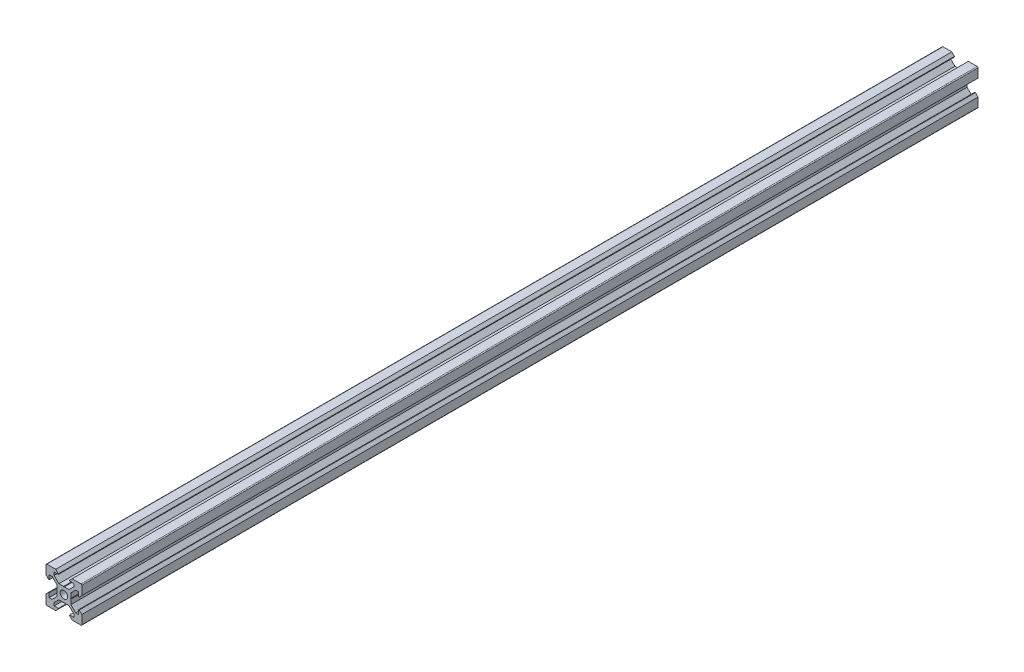
from build123d import *

# Parameters (mm, degrees)
SKETCH1_R           = 2.1
BOSS_EXTRUDE1_DEPTH = 500


with BuildPart() as part:
    # Sketch1 → Boss-Extrude1 (new body)
    with BuildSketch(Plane.XY):
        with BuildLine():
            Line((4.58, -10), (9.5, -10))
            ThreePointArc((9.5, -10), (9.853553391, -9.853553391), (10, -9.5))
            Line((10, -9.5), (10, -4.58))
            Line((10, -4.58), (8.545, -3.125))
            Line((8.545, -3.125), (8.2, -3.125))
            Line((8.2, -3.125), (8.2, -5.5))
            Line((8.2, -5.5), (6.560660172, -5.5))
            Line((6.560660172, -5.5), (3.9, -2.839339828))
            Line((3.9, -2.839339828), (3.9, -0.21))
            Line((3.9, -0.21), (3.69, 0))
            Line((3.69, 0), (3.9, 0.21))
            Line((3.9, 0.21), (3.9, 2.839339828))
            Line((3.9, 2.839339828), (6.560660172, 5.5))
            Line((6.560660172, 5.5), (8.2, 5.5))
            Line((8.2, 5.5), (8.2, 3.125))
            Line((8.2, 3.125), (8.545, 3.125))
            Line((8.545, 3.125), (10, 4.58))
            Line((10, 4.58), (10, 9.5))
            ThreePointArc((10, 9.5), (9.853553391, 9.853553391), (9.5, 10))
            Line((9.5, 10), (4.58, 10))
            Line((4.58, 10), (3.125, 8.545))
            Line((3.125, 8.545), (3.125, 8.2))
            Line((3.125, 8.2), (5.5, 8.2))
            Line((5.5, 8.2), (5.5, 6.560660172))
            Line((5.5, 6.560660172), (2.839339828, 3.9))
            Line((2.839339828, 3.9), (0.21, 3.9))
            Line((0.21, 3.9), (0, 3.69))
            Line((0, 3.69), (-0.21, 3.9))
            Line((-0.21, 3.9), (-2.839339828, 3.9))
            Line((-2.839339828, 3.9), (-5.5, 6.560660172))
            Line((-5.5, 6.560660172), (-5.5, 8.2))
            Line((-5.5, 8.2), (-3.125, 8.2))
            Line((-3.125, 8.2), (-3.125, 8.545))
            Line((-3.125, 8.545), (-4.58, 10))
            Line((-4.58, 10), (-9.5, 10))
            ThreePointArc((-9.5, 10), (-9.853553391, 9.853553391), (-10, 9.5))
            Line((-10, 9.5), (-10, 4.58))
            Line((-10, 4.58), (-8.545, 3.125))
            Line((-8.545, 3.125), (-8.2, 3.125))
            Line((-8.2, 3.125), (-8.2, 5.5))
            Line((-8.2, 5.5), (-6.560660172, 5.5))
            Line((-6.560660172, 5.5), (-3.9, 2.839339828))
            Line((-3.9, 2.839339828), (-3.9, 0.21))
            Line((-3.9, 0.21), (-3.69, 0))
            Line((-3.69, 0), (-3.9, -0.21))
            Line((-3.9, -0.21), (-3.9, -2.839339828))
            Line((-3.9, -2.839339828), (-6.560660172, -5.5))
            Line((-6.560660172, -5.5), (-8.2, -5.5))
            Line((-8.2, -5.5), (-8.2, -3.125))
            Line((-8.2, -3.125), (-8.545, -3.125))
            Line((-8.545, -3.125), (-10, -4.58))
            Line((-10, -4.58), (-10, -9.5))
            ThreePointArc((-10, -9.5), (-9.853553391, -9.853553391), (-9.5, -10))
            Line((-9.5, -10), (-4.58, -10))
            Line((-4.58, -10), (-3.125, -8.545))
            Line((-3.125, -8.545), (-3.125, -8.2))
            Line((-3.125, -8.2), (-5.5, -8.2))
            Line((-5.5, -8.2), (-5.5, -6.560660172))
            Line((-5.5, -6.560660172), (-2.839339828, -3.9))
            Line((-2.839339828, -3.9), (-0.21, -3.9))
            Line((-0.21, -3.9), (0, -3.69))
            Line((0, -3.69), (0.21, -3.9))
            Line((0.21, -3.9), (2.839339828, -3.9))
            Line((2.839339828, -3.9), (5.5, -6.560660172))
            Line((5.5, -6.560660172), (5.5, -8.2))
            Line((5.5, -8.2), (3.125, -8.2))
            Line((3.125, -8.2), (3.125, -8.545))
            Line((3.125, -8.545), (4.58, -10))
        make_face()
        Circle(SKETCH1_R, mode=Mode.SUBTRACT)
    extrude(amount=BOSS_EXTRUDE1_DEPTH)


solid = part.part
